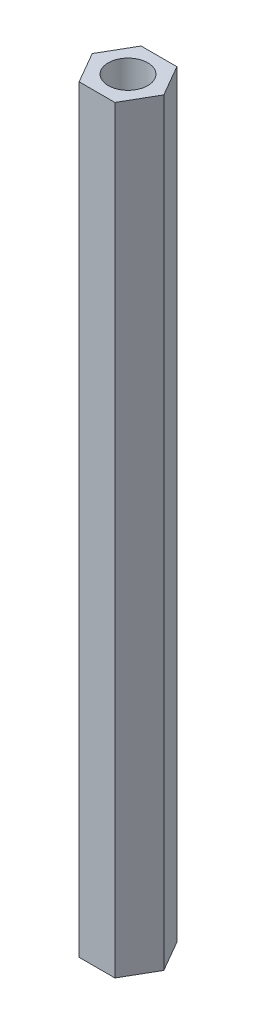
from build123d import *

# Parameters (mm, degrees)
SKETCH2_R           = 1.5
BOSS_EXTRUDE1_DEPTH = 57.5


with BuildPart() as part:
    # Sketch2 → Boss-Extrude1 (new body)
    with BuildSketch(Plane(origin=(0, 0, 0), x_dir=(1, 0, 0), z_dir=(0, 1, 0))):
        Polygon((2.713546265, 0), (1.356773133, 2.35), (-1.356773133, 2.35), (-2.713546265, 0), (-1.356773133, -2.35), (1.356773133, -2.35), align=None)
        Circle(SKETCH2_R, mode=Mode.SUBTRACT)
    extrude(amount=BOSS_EXTRUDE1_DEPTH)


solid = part.part
